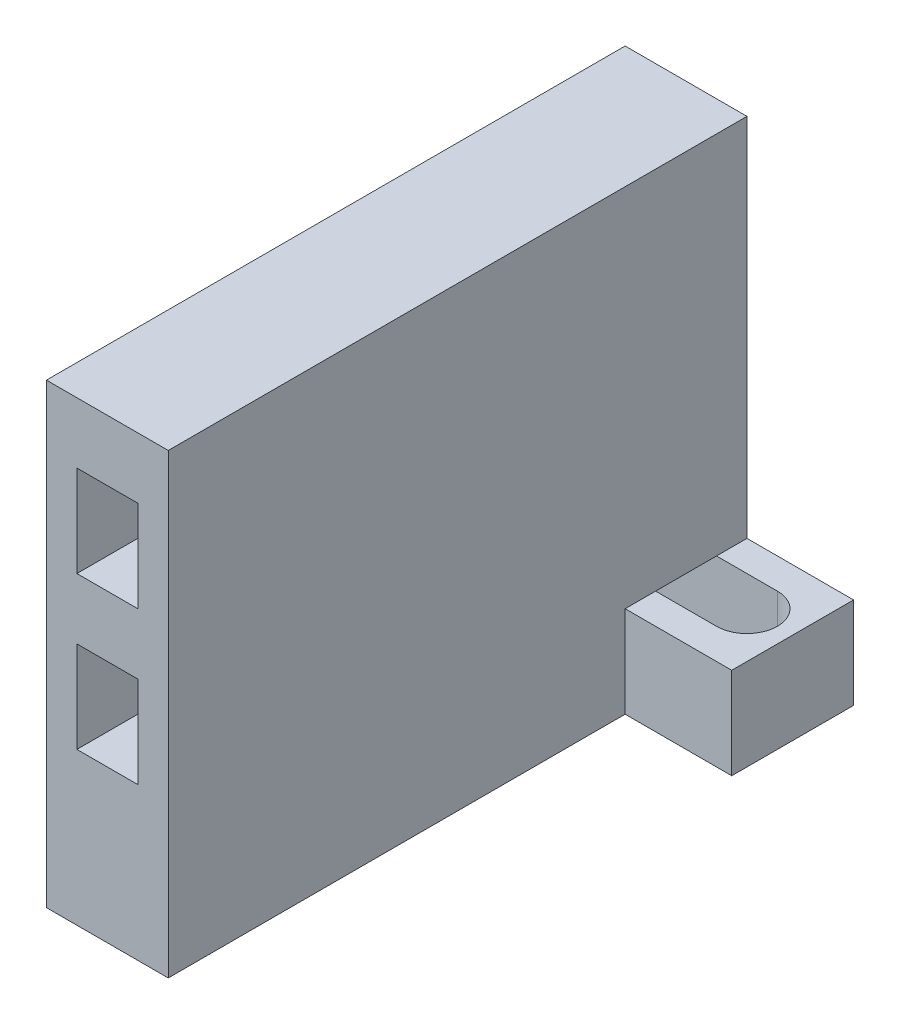
from build123d import *

# Parameters (mm, degrees)
SKETCH_1_W          = 4
SKETCH_1_H          = 6
EXTRUDE_1_DEPTH     = 8
EXTRUDE_START       = 8
SKETCH_1_3_W        = 4
SKETCH_1_3_H        = 6
EXTRUDE_2_DEPTH     = 30
CUT_EXTRUDE_1_DEPTH = 6


with BuildPart() as part:
    # Эскиз1 → Бобышка-Вытянуть1 (new body)
    with BuildSketch(Plane.XY):
        Polygon((0, 30), (0, 0), (15, 0), (15, 6), (8, 6), (8, 30), align=None)
        with Locations((4, 23)):
            Rectangle(SKETCH_1_W, SKETCH_1_H, mode=Mode.SUBTRACT)
        with Locations((4, 13)):
            Rectangle(SKETCH_1_W, SKETCH_1_H, mode=Mode.SUBTRACT)
    extrude(amount=EXTRUDE_1_DEPTH)

    # Эскиз1<3> → Бобышка-Вытянуть2 (add)
    with BuildSketch(Plane.XY.offset(EXTRUDE_START)):
        Polygon((8, 30), (4, 30), (4, 26), (6, 26), (6, 20), (4, 20), (4, 16), (6, 16), (6, 10), (4, 10), (4, 6), (8, 6), align=None)
        Polygon((4, 30), (0, 30), (0, 6), (4, 6), (4, 10), (2, 10), (2, 16), (4, 16), (4, 20), (2, 20), (2, 26), (4, 26), align=None)
        with Locations((2, 3)):
            Rectangle(SKETCH_1_3_W, SKETCH_1_3_H)
        with Locations((6, 3)):
            Rectangle(SKETCH_1_3_W, SKETCH_1_3_H)
    extrude(amount=EXTRUDE_2_DEPTH)

    # Эскиз2 → Вырез-Вытянуть1 (cut)
    with BuildSketch(Plane.XZ):
        with BuildLine():
            Line((4, 2), (12, 2))
            ThreePointArc((12, 2), (14, 4), (12, 6))
            Line((12, 6), (4, 6))
            ThreePointArc((4, 6), (2, 4), (4, 2))
        make_face()
    extrude(amount=-CUT_EXTRUDE_1_DEPTH, mode=Mode.SUBTRACT)


solid = part.part
